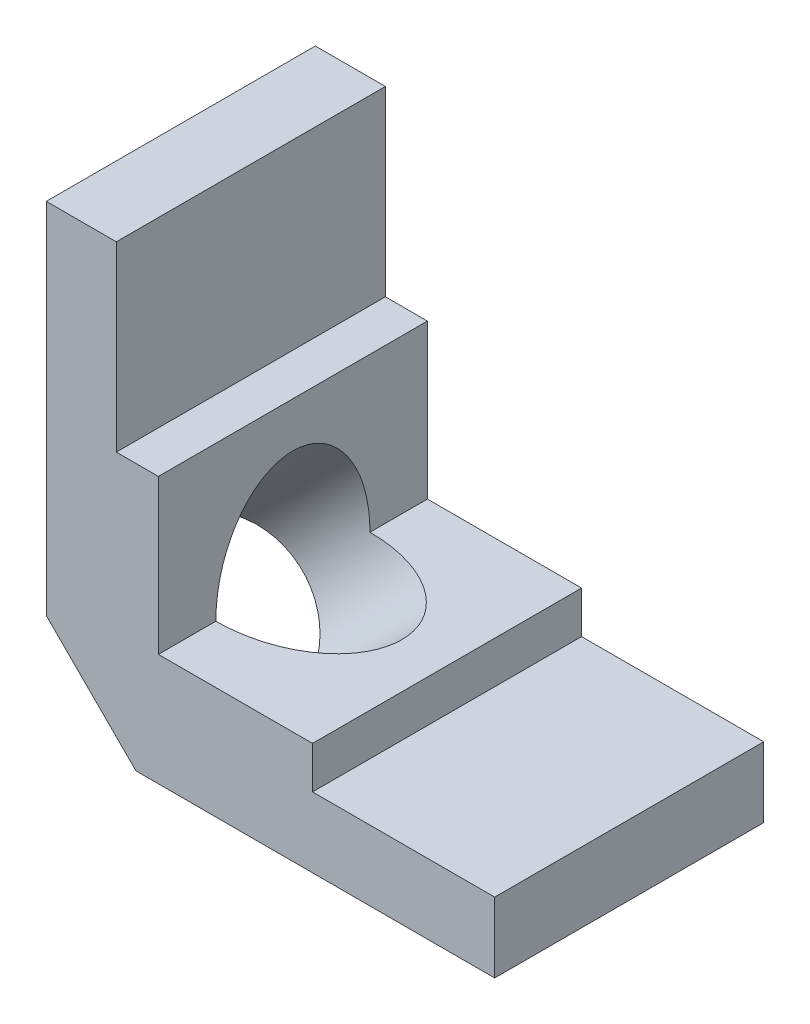
from build123d import *

# Parameters (mm, degrees)
BOSS_EXTRUDE1_DEPTH              = 7.62
SKETCH2_W                        = 15.24
SKETCH2_H                        = 10.31875
CUT_EXTRUDE1_DEPTH               = 2.38125
SKETCH4_W                        = 10.31875
SKETCH4_H                        = 15.24
CUT_EXTRUDE2_DEPTH               = 2.38125
CHAMFER1_SIZE                    = 5.08
F_11_32_0_34375_DIAMETER_HOLE1_D = 8.73125


with BuildPart() as part:
    # Sketch1 → Boss-Extrude1 (new body, symmetric)
    with BuildSketch(Plane.XY):
        Polygon((0, 0), (0, 25.4), (6.35, 25.4), (6.35, 6.35), (25.4, 6.35), (25.4, 0), align=None)
    extrude(amount=BOSS_EXTRUDE1_DEPTH, both=True)

    # Sketch2 → Cut-Extrude1 (cut)
    with BuildSketch(Plane(origin=(6.35, 0, 0), x_dir=(0, 0, -1), z_dir=(1, 0, 0))):
        with Locations((0, 20.240625)):
            Rectangle(SKETCH2_W, SKETCH2_H)
    extrude(amount=-CUT_EXTRUDE1_DEPTH, mode=Mode.SUBTRACT)

    # Sketch4 → Cut-Extrude2 (cut)
    with BuildSketch(Plane(origin=(0, 6.35, 0), x_dir=(1, 0, 0), z_dir=(0, 1, 0))):
        with Locations((20.240625, 0)):
            Rectangle(SKETCH4_W, SKETCH4_H)
    extrude(amount=-CUT_EXTRUDE2_DEPTH, mode=Mode.SUBTRACT)

    # Chamfer1
    chamfer1_edges = [part.edges().sort_by_distance(p)[0] for p in [
        (0, 0, 0),
    ]]
    chamfer(chamfer1_edges, length=CHAMFER1_SIZE)

    # 11/32 (0.34375) Diameter Hole1 (through all)
    with Locations(Plane(origin=(2.54, 2.54, 0), x_dir=(0, 0, 1), z_dir=(-0.707106781, -0.707106781, 0))):
        with Locations((0, 0)):
            Hole(F_11_32_0_34375_DIAMETER_HOLE1_D / 2)


solid = part.part
